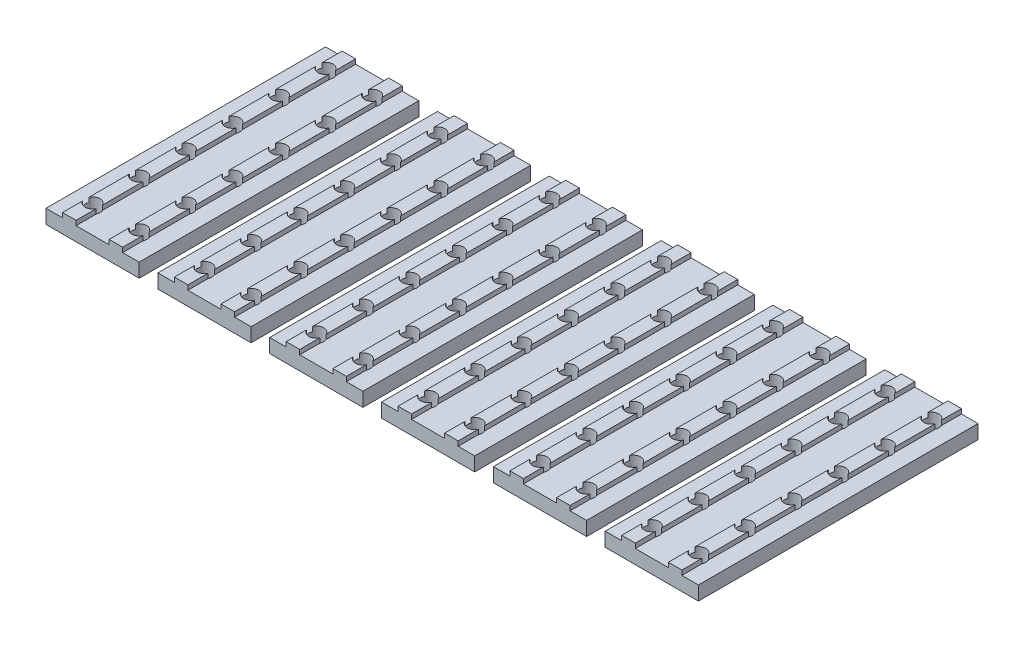
from build123d import *

# Parameters (mm, degrees)
MAIN_DEPTH                      = 20
ESQUISSE2_R                     = 1.6
TOPHOLE_DEPTH                   = 22
R_P_TITION_LIN_AIRE1_COUNT      = 3
R_P_TITION_LIN_AIRE1_PITCH      = 20
R_P_TITION_LIN_AIRE1_COUNT_DIR2 = 2
R_P_TITION_LIN_AIRE1_PITCH_DIR2 = 10
LPATTERN1_COUNT                 = 6
LPATTERN1_PITCH                 = 24


with BuildPart() as part:
    # Esquisse1 → Main (new body)
    with BuildSketch(Plane.XY):
        Polygon((-5, 0), (-5, 3), (-1.45, 3), (-1.45, 4), (1.45, 4), (1.45, 3), (5, 3), (5, 0), align=None)
    main = extrude(amount=MAIN_DEPTH)

    # Esquisse2 → TopHole (cut, through all)
    with BuildSketch(Plane(origin=(0, 4, 0), x_dir=(1, 0, 0), z_dir=(0, 1, 0))):
        with Locations((0, -5)):
            Circle(ESQUISSE2_R)
        with Locations((0, -15)):
            Circle(ESQUISSE2_R)
    tophole = extrude(amount=-TOPHOLE_DEPTH, mode=Mode.SUBTRACT)

    # Répétition linéaire1: Main, TopHole 3 × 2
    with Locations(*[(-j * R_P_TITION_LIN_AIRE1_PITCH_DIR2, 0, i * R_P_TITION_LIN_AIRE1_PITCH) for i in range(R_P_TITION_LIN_AIRE1_COUNT) for j in range(R_P_TITION_LIN_AIRE1_COUNT_DIR2) if (i, j) != (0, 0)]):
        add(main)
        add(tophole, mode=Mode.SUBTRACT)


with BuildPart() as lpattern1_1:
    # LPattern1: pattern copy
    add(part.part.moved(Location(Vector(1, 0, 0) * (1 * LPATTERN1_PITCH))))


with BuildPart() as lpattern1_2:
    # LPattern1: pattern copy
    add(part.part.moved(Location(Vector(1, 0, 0) * (2 * LPATTERN1_PITCH))))


with BuildPart() as lpattern1_3:
    # LPattern1: pattern copy
    add(part.part.moved(Location(Vector(1, 0, 0) * (3 * LPATTERN1_PITCH))))


with BuildPart() as lpattern1_4:
    # LPattern1: pattern copy
    add(part.part.moved(Location(Vector(1, 0, 0) * (4 * LPATTERN1_PITCH))))


with BuildPart() as lpattern1_5:
    # LPattern1: pattern copy
    add(part.part.moved(Location(Vector(1, 0, 0) * (5 * LPATTERN1_PITCH))))


solid = Compound([part.part, lpattern1_1.part, lpattern1_2.part, lpattern1_3.part, lpattern1_4.part, lpattern1_5.part])
